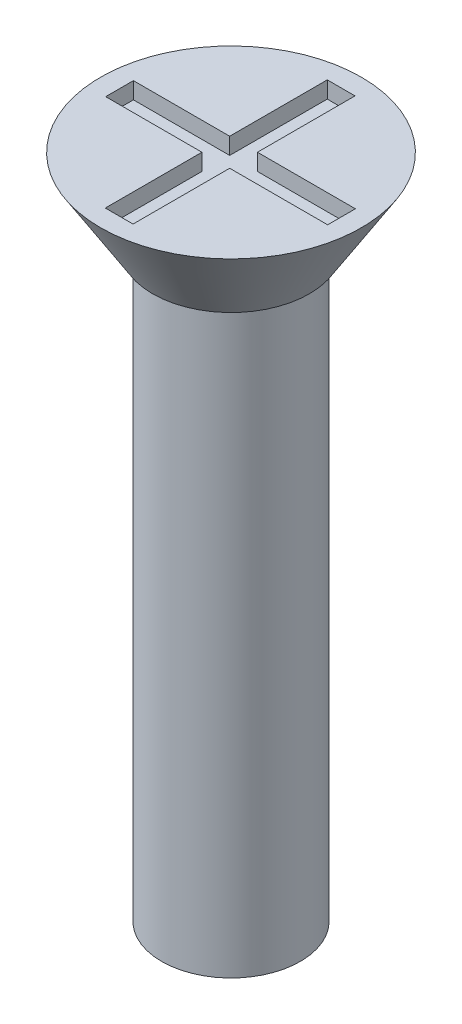
from build123d import *

# Parameters (mm, degrees)
SKETCH1_R           = 1.25
BOSS_EXTRUDE1_DEPTH = 12
SKETCH2_R           = 2.35
BOSS_EXTRUDE2_DEPTH = 1.5
BOSS_EXTRUDE2_TAPER = 32
SKETCH3_W           = 0.5
SKETCH3_H           = 1.758378485
SKETCH3_H_2         = 1.741621515
SKETCH3_W_2         = 1.734727157
SKETCH3_H_3         = 0.5
SKETCH3_W_3         = 1.765272843
CUT_EXTRUDE1_DEPTH  = 0.3


with BuildPart() as part:
    # Sketch1 → Boss-Extrude1 (new body)
    with BuildSketch(Plane(origin=(0, 0, 0), x_dir=(1, 0, 0), z_dir=(0, 1, 0))):
        Circle(SKETCH1_R)
    extrude(amount=BOSS_EXTRUDE1_DEPTH)

    # Sketch2 → Boss-Extrude2 (add)
    with BuildSketch(Plane(origin=(0, 12, 0), x_dir=(1, 0, 0), z_dir=(0, 1, 0))):
        Circle(SKETCH2_R)
    extrude(amount=-BOSS_EXTRUDE2_DEPTH, taper=BOSS_EXTRUDE2_TAPER)

    # Sketch3 → Cut-Extrude1 (cut)
    with BuildSketch(Plane(origin=(0, 12, 0), x_dir=(1, 0, 0), z_dir=(0, 1, 0))):
        with Locations((-0.015272843, 1.120810757)):
            Rectangle(SKETCH3_W, SKETCH3_H)
        with Locations((-0.015272843, -1.129189243)):
            Rectangle(SKETCH3_W, SKETCH3_H_2)
        with Locations((-1.132636421, -0.008378485)):
            Rectangle(SKETCH3_W_2, SKETCH3_H_3)
        with Locations((1.117363579, -0.008378485)):
            Rectangle(SKETCH3_W_3, SKETCH3_H_3)
        with Locations((-0.015272843, -0.008378485)):
            Rectangle(SKETCH3_W, SKETCH3_H_3)
    extrude(amount=-CUT_EXTRUDE1_DEPTH, mode=Mode.SUBTRACT)


solid = part.part
